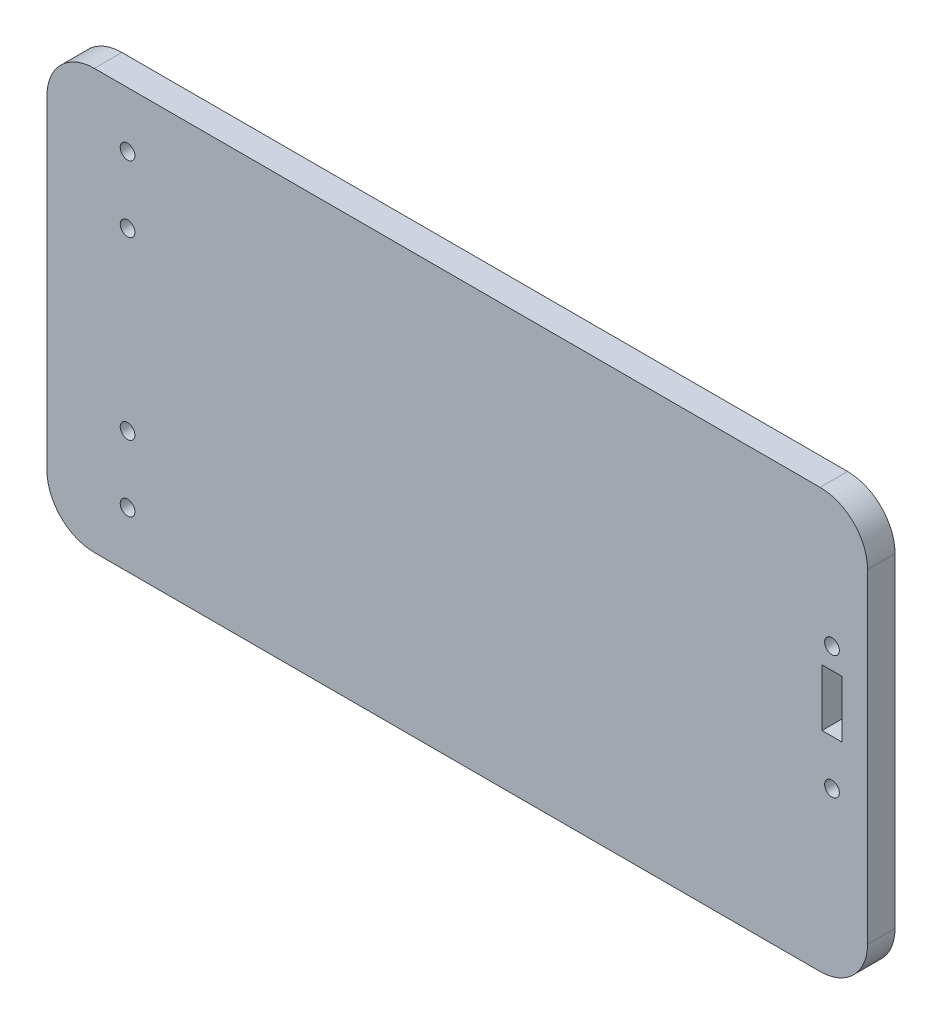
from build123d import *

# Parameters (mm, degrees)
BOSS_EXTRUDE1_DEPTH = 5.8
SKETCH3_W           = 4.2
SKETCH3_H           = 12
CUT_EXTRUDE1_DEPTH  = 6.35
SKETCH4_R           = 1.55
CUT_EXTRUDE2_DEPTH  = 6.8
SKETCH5_R           = 1.55
CUT_EXTRUDE3_DEPTH  = 6.8


with BuildPart() as part:
    # Sketch2 → Boss-Extrude1 (new body)
    with BuildSketch(Plane.XY):
        with BuildLine():
            Line((163, 44.2), (10, 44.2))
            ThreePointArc((10, 44.2), (2.928932188, 41.271067812), (0, 34.2))
            Line((0, 34.2), (0, -34.2))
            ThreePointArc((0, -34.2), (2.928932188, -41.271067812), (10, -44.2))
            Line((10, -44.2), (163, -44.2))
            ThreePointArc((163, -44.2), (170.071067812, -41.271067812), (173, -34.2))
            Line((173, -34.2), (173, 34.2))
            ThreePointArc((173, 34.2), (170.071067812, 41.271067812), (163, 44.2))
        make_face()
    extrude(amount=BOSS_EXTRUDE1_DEPTH)

    # Sketch3 → Cut-Extrude1 (cut)
    with BuildSketch(Plane.XY.offset(5.8)):
        with Locations((165.5, 6)):
            Rectangle(SKETCH3_W, SKETCH3_H)
    extrude(amount=-CUT_EXTRUDE1_DEPTH, mode=Mode.SUBTRACT)

    # Sketch4 → Cut-Extrude2 (cut, through all)
    with BuildSketch(Plane.XY.offset(5.8)):
        with Locations((17, 32.5)):
            Circle(SKETCH4_R)
        with Locations((17, 18.5)):
            Circle(SKETCH4_R)
        with Locations((17, -18.5)):
            Circle(SKETCH4_R)
        with Locations((17, -32.5)):
            Circle(SKETCH4_R)
    extrude(amount=-CUT_EXTRUDE2_DEPTH, mode=Mode.SUBTRACT)

    # Sketch5 → Cut-Extrude3 (cut, through all)
    with BuildSketch(Plane.XY.offset(5.8)):
        with Locations((165.5, 16.45)):
            Circle(SKETCH5_R)
        with Locations((165.5, -9.55)):
            Circle(SKETCH5_R)
    extrude(amount=-CUT_EXTRUDE3_DEPTH, mode=Mode.SUBTRACT)


solid = part.part
